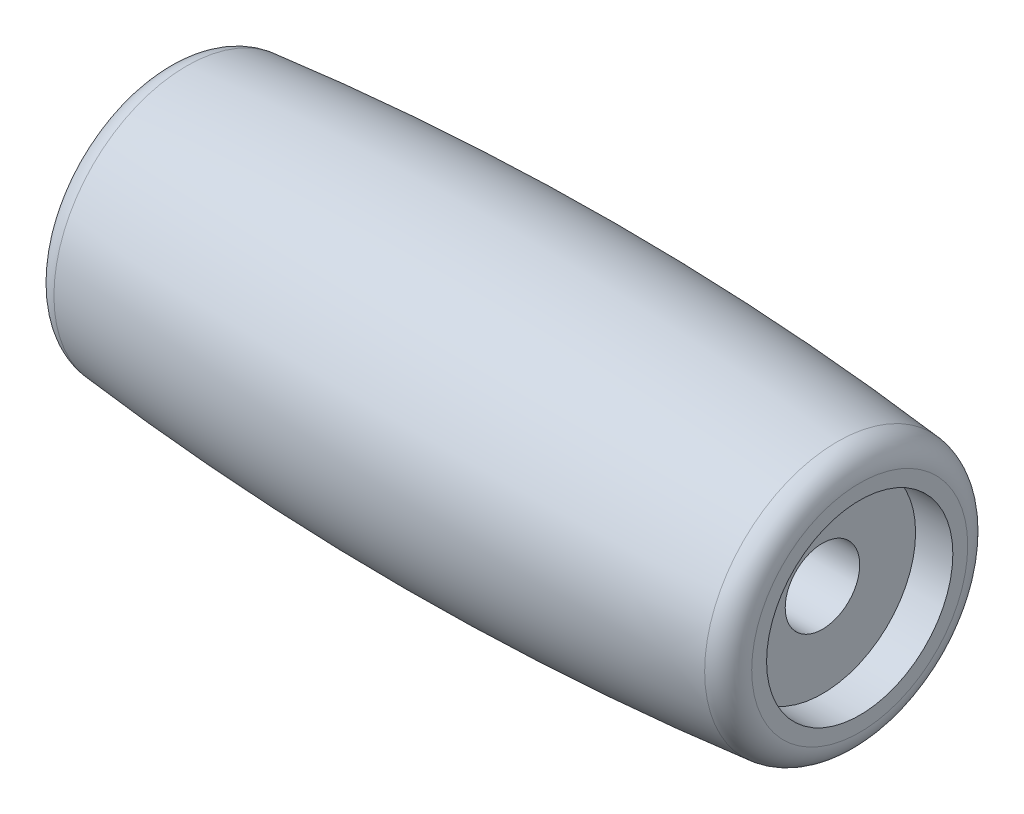
from build123d import *

# Parameters (mm, degrees)
SCALE1_SCALE = 1.7


with BuildPart() as part:
    # Sketch1 → Revolve1 (revolve)
    with BuildSketch(Plane.XY):
        with BuildLine():
            Line((-12.5, 1.5), (12.5, 1.5))
            Line((12.5, 1.5), (12.5, 3.75))
            Line((12.5, 3.75), (14, 3.75))
            Line((14, 3.75), (14, 4.348576665))
            ThreePointArc((14, 4.348576665), (13.741609048, 5.019408999), (13.099967959, 5.343567322))
            ThreePointArc((13.099967959, 5.343567322), (0, 6), (-13.099967959, 5.343567322))
            ThreePointArc((-13.099967959, 5.343567322), (-13.741609048, 5.019408999), (-14, 4.348576665))
            Line((-14, 4.348576665), (-14, 3.75))
            Line((-14, 3.75), (-12.5, 3.75))
            Line((-12.5, 3.75), (-12.5, 1.5))
        make_face()
    revolve(axis=Axis((0, 0, 0), (1, 0, 0)))


with BuildPart() as part_1:
    # Scale1: scaled about (0, 0, 0)
    add(part.part.scale(SCALE1_SCALE))


solid = part_1.part
